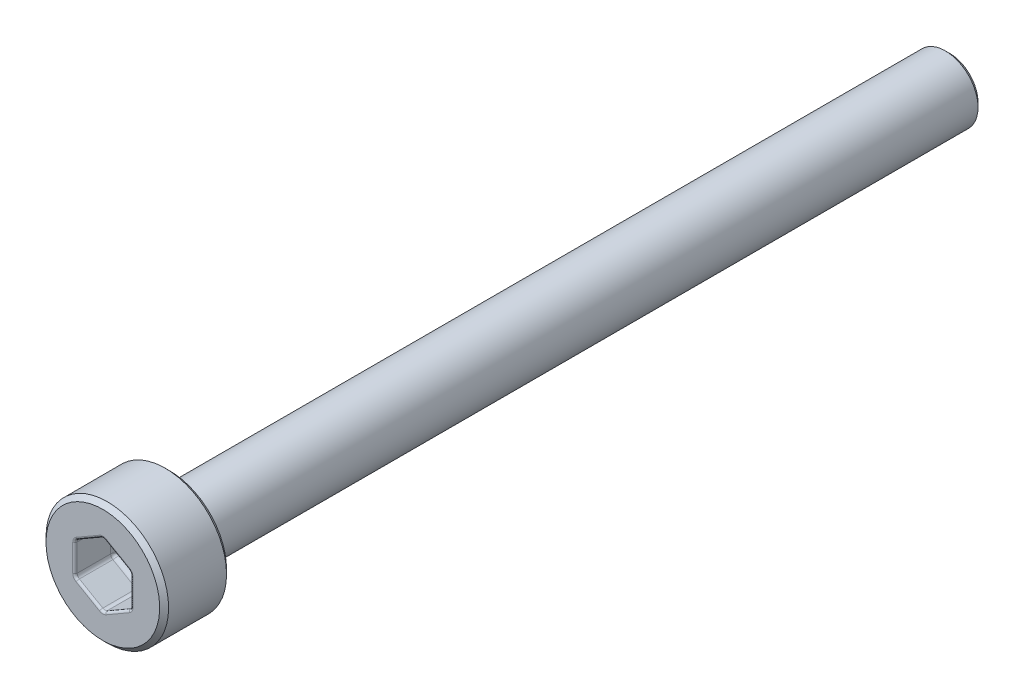
from build123d import *

# Parameters (mm, degrees)
SCHNITT_LINEAR_AUSTRAGEN1_DEPTH = 1.8
FASE1_SIZE                      = 0.2
VERRUNDUNG1_R                   = 0.2
VERRUNDUNG2_R                   = 0.1


with BuildPart() as part:
    # Skizze1 → Rotation1 (revolve)
    with BuildSketch(Plane(origin=(0, 0, 0), x_dir=(0, 0, -1), z_dir=(1, 0, 0))):
        Polygon((-3, 0), (-3, 2.75), (0, 2.75), (0, 1.465), (35, 1.465), (35, 0), align=None)
    revolve(axis=Axis((0, 0, 21.919879518), (0, 0, -1)))

    # Skizze2 → Schnitt-Linear austragen1 (cut)
    with BuildSketch(Plane.XY.offset(3)):
        Polygon((1.25, -0.721687836), (1.25, 0.721687836), (0, 1.443375673), (-1.25, 0.721687836), (-1.25, -0.721687836), (0, -1.443375673), align=None)
    extrude(amount=-SCHNITT_LINEAR_AUSTRAGEN1_DEPTH, mode=Mode.SUBTRACT)

    # Fase1
    fase1_edges = [part.edges().sort_by_distance(p)[0] for p in [
        (0, -2.75, 3),
        (0, -2.75, 0),
        (0, -1.465, -35),
    ]]
    chamfer(fase1_edges, length=FASE1_SIZE)

    # Verrundung1
    verrundung1_edges = [part.edges().sort_by_distance(p)[0] for p in [
        (-0.625, -1.082531755, 1.2),
        (-1.25, 0, 1.2),
        (-0.625, 1.082531755, 1.2),
        (0.625, 1.082531755, 1.2),
        (1.25, 0, 1.2),
        (0.625, -1.082531755, 1.2),
        (-1.25, -0.721687836, 2.1),
        (0, -1.443375673, 2.1),
        (1.25, -0.721687836, 2.1),
        (1.25, 0.721687836, 2.1),
        (0, 1.443375673, 2.1),
        (-1.25, 0.721687836, 2.1),
        (0, -1.465, 0),
    ]]
    fillet(verrundung1_edges, radius=VERRUNDUNG1_R)

    # Verrundung2
    verrundung2_edges = [part.edges().sort_by_distance(p)[0] for p in [
        (1.223205081, -0.706217783, 3),
        (0.625, -1.082531755, 3),
        (0, -1.412435565, 3),
        (-0.625, -1.082531755, 3),
        (-1.223205081, -0.706217783, 3),
        (-1.25, 0, 3),
        (-1.223205081, 0.706217783, 3),
        (-0.625, 1.082531755, 3),
        (0, 1.412435565, 3),
        (0.625, 1.082531755, 3),
        (1.223205081, 0.706217783, 3),
        (1.25, 0, 3),
    ]]
    fillet(verrundung2_edges, radius=VERRUNDUNG2_R)


solid = part.part
